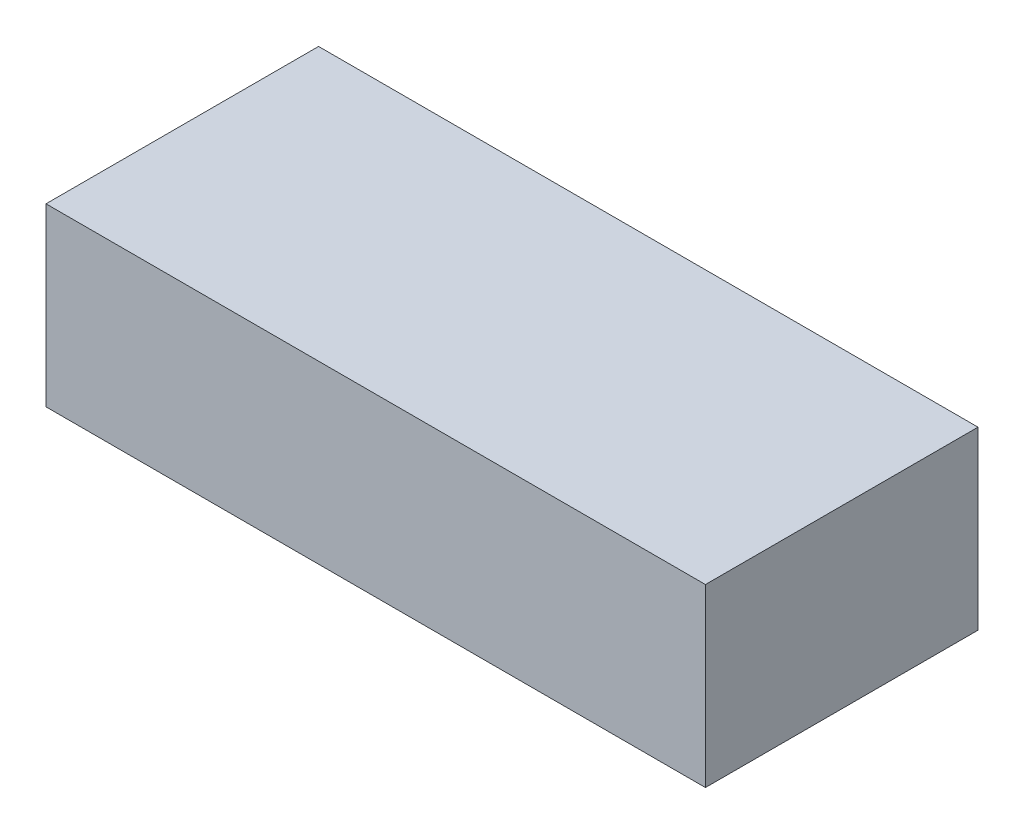
from build123d import *

# Parameters (mm, degrees)
CROQUIS1_W              = 75
CROQUIS1_H              = 31
SALIENTE_EXTRUIR1_DEPTH = 20


with BuildPart() as part:
    # Croquis1 → Saliente-Extruir1 (new body)
    with BuildSketch(Plane(origin=(0, 0, 0), x_dir=(1, 0, 0), z_dir=(0, 1, 0))):
        Rectangle(CROQUIS1_W, CROQUIS1_H)
    extrude(amount=SALIENTE_EXTRUIR1_DEPTH)


solid = part.part
